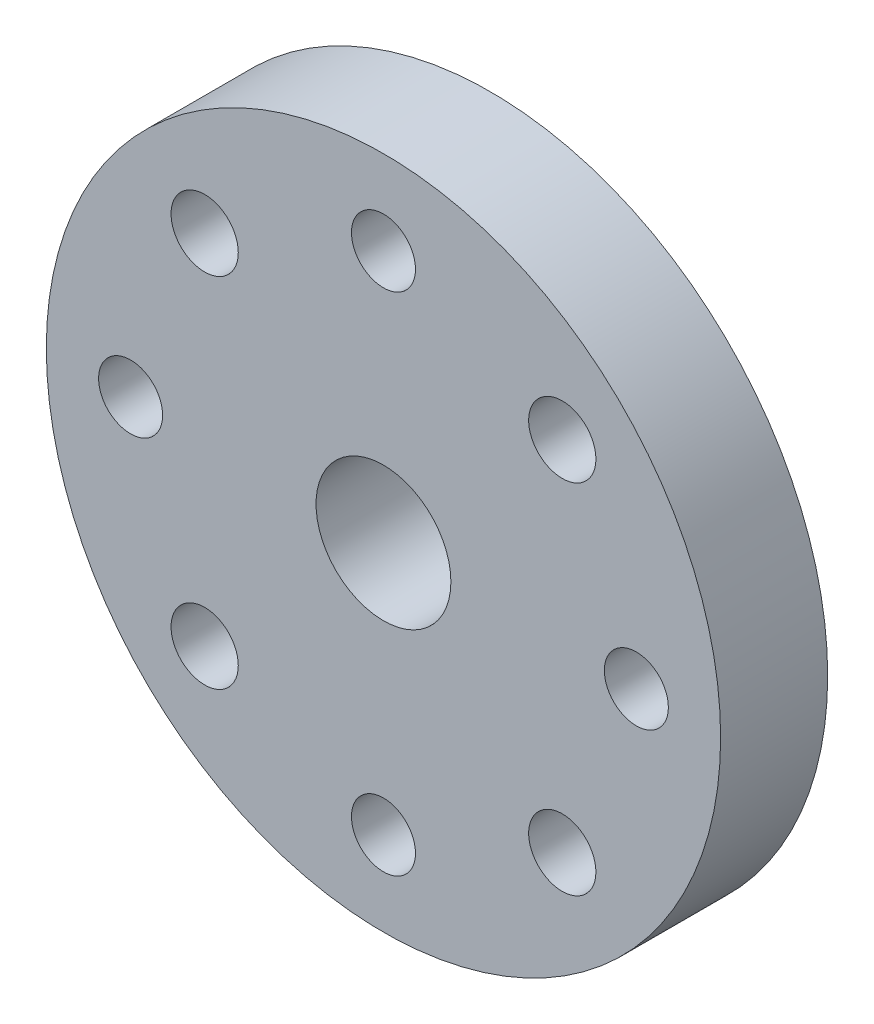
from build123d import *

# Parameters (mm, degrees)
SKETCH1_R           = 20
SKETCH1_R_2         = 4
SKETCH1_R_3         = 1.89865
SKETCH1_R_4         = 1.9939
BOSS_EXTRUDE1_DEPTH = 6.35


with BuildPart() as part:
    # Sketch1 → Boss-Extrude1 (new body)
    with BuildSketch(Plane.XY):
        Circle(SKETCH1_R)
        Circle(SKETCH1_R_2, mode=Mode.SUBTRACT)
        with Locations((0, 15)):
            Circle(SKETCH1_R_3, mode=Mode.SUBTRACT)
        with Locations((10.606601718, 10.606601718)):
            Circle(SKETCH1_R_4, mode=Mode.SUBTRACT)
        with Locations((15, 0)):
            Circle(SKETCH1_R_3, mode=Mode.SUBTRACT)
        with Locations((10.606601718, -10.606601718)):
            Circle(SKETCH1_R_4, mode=Mode.SUBTRACT)
        with Locations((0, -15)):
            Circle(SKETCH1_R_3, mode=Mode.SUBTRACT)
        with Locations((-10.606601718, -10.606601718)):
            Circle(SKETCH1_R_4, mode=Mode.SUBTRACT)
        with Locations((-15, 0)):
            Circle(SKETCH1_R_3, mode=Mode.SUBTRACT)
        with Locations((-10.606601718, 10.606601718)):
            Circle(SKETCH1_R_4, mode=Mode.SUBTRACT)
    extrude(amount=BOSS_EXTRUDE1_DEPTH)


solid = part.part
